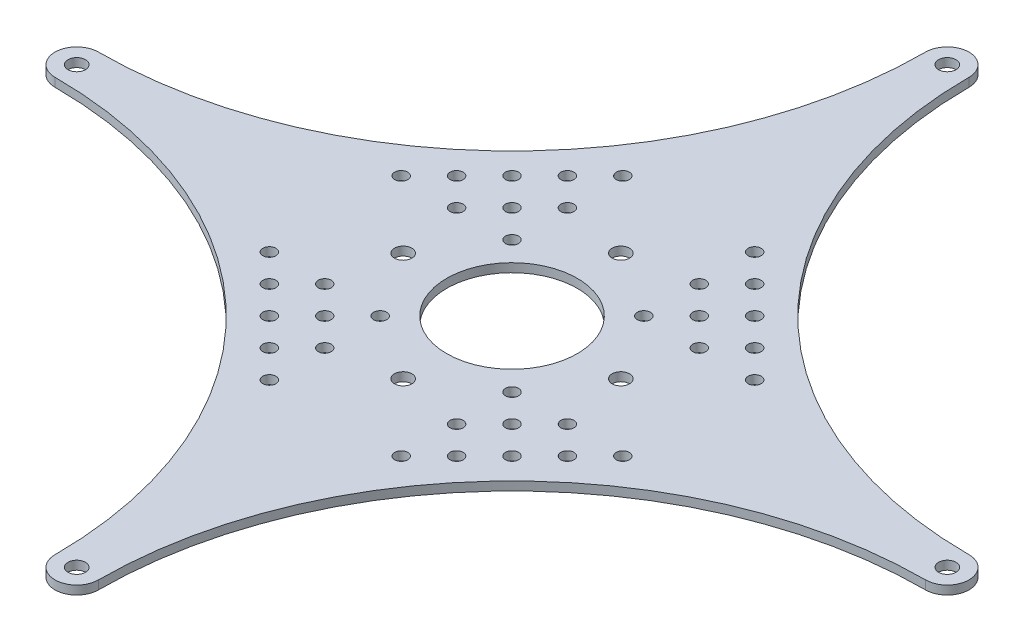
from build123d import *

# Parameters (mm, degrees)
EXTRUDE_887_DEPTH           = 2
SKETCH_2_R                  = 2
CUT_EXTRUDE_1122_DEPTH      = 3
PATTERN_CIRCULAR_1192_COUNT = 4
SKETCH_4_R                  = 15
CUT_EXTRUDE_1537_DEPTH      = 3
SKETCH_5_R                  = 1.5
CUT_EXTRUDE_2052_DEPTH      = 3
PATTERN_CIRCULAR_2_COUNT    = 4


with BuildPart() as part:
    # Эскиз1 → Extrude 887 (new body)
    with BuildSketch(Plane(origin=(0, 0, 0), x_dir=(1, 0, 0), z_dir=(0, 1, 0))):
        with BuildLine():
            ThreePointArc((-5, 100), (0, 105), (5, 100))
            ThreePointArc((5, 100), (32.824855787, 32.824855787), (100, 5))
            ThreePointArc((100, 5), (105, 0), (100, -5))
            ThreePointArc((100, -5), (32.824855787, -32.824855787), (5, -100))
            ThreePointArc((5, -100), (0, -105), (-5, -100))
            ThreePointArc((-5, -100), (-32.824855787, -32.824855787), (-100, -5))
            ThreePointArc((-100, -5), (-105, 0), (-100, 5))
            ThreePointArc((-100, 5), (-32.824855787, 32.824855787), (-5, 100))
        make_face()
    extrude(amount=EXTRUDE_887_DEPTH)

    # Эскиз2 → Cut-Extrude 1122 (cut, through all)
    with BuildSketch(Plane(origin=(0, 2, 0), x_dir=(1, 0, 0), z_dir=(0, 1, 0))):
        with Locations((100, 0)):
            Circle(SKETCH_2_R)
        with Locations((25, 0)):
            Circle(SKETCH_2_R)
    cut_extrude_1122 = extrude(amount=-CUT_EXTRUDE_1122_DEPTH, mode=Mode.SUBTRACT)

    # Pattern Circular 1192: Cut-Extrude 1122 ×4 about axis
    pattern_circular_1192_axis = Axis((0, 0, 0), (0, 1, 0))
    for i in range(1, PATTERN_CIRCULAR_1192_COUNT):
        add(cut_extrude_1122.rotate(pattern_circular_1192_axis, i * 360 / PATTERN_CIRCULAR_1192_COUNT), mode=Mode.SUBTRACT)

    # Эскиз4 → Cut-Extrude 1537 (cut, through all)
    with BuildSketch(Plane(origin=(0, 2, 0), x_dir=(1, 0, 0), z_dir=(0, 1, 0))):
        Circle(SKETCH_4_R)
    extrude(amount=-CUT_EXTRUDE_1537_DEPTH, mode=Mode.SUBTRACT)

    # Эскиз5 → Cut-Extrude 2052 (cut, through all)
    with BuildSketch(Plane(origin=(0, 2, 0), x_dir=(1, 0, 0), z_dir=(0, 1, 0))):
        with Locations((40.60303038, 15.147186258)):
            Circle(SKETCH_5_R)
        with Locations((27.875108319, 15.147186258)):
            Circle(SKETCH_5_R)
        with Locations((21.511147288, 21.511147288)):
            Circle(SKETCH_5_R)
        with Locations((15.147186258, 15.147186258)):
            Circle(SKETCH_5_R)
        with Locations((15.147186258, 27.875108319)):
            Circle(SKETCH_5_R)
        with Locations((34.23906935, 21.511147288)):
            Circle(SKETCH_5_R)
        with Locations((27.875108319, 27.875108319)):
            Circle(SKETCH_5_R)
        with Locations((21.511147288, 34.23906935)):
            Circle(SKETCH_5_R)
        with Locations((15.147186258, 40.60303038)):
            Circle(SKETCH_5_R)
    cut_extrude_2052 = extrude(amount=-CUT_EXTRUDE_2052_DEPTH, mode=Mode.SUBTRACT)

    # Круговой массив2: Cut-Extrude 2052 ×4 about axis
    pattern_circular_2_axis = Axis((0, 0, 0), (0, 1, 0))
    for i in range(1, PATTERN_CIRCULAR_2_COUNT):
        add(cut_extrude_2052.rotate(pattern_circular_2_axis, i * 360 / PATTERN_CIRCULAR_2_COUNT), mode=Mode.SUBTRACT)


solid = part.part
